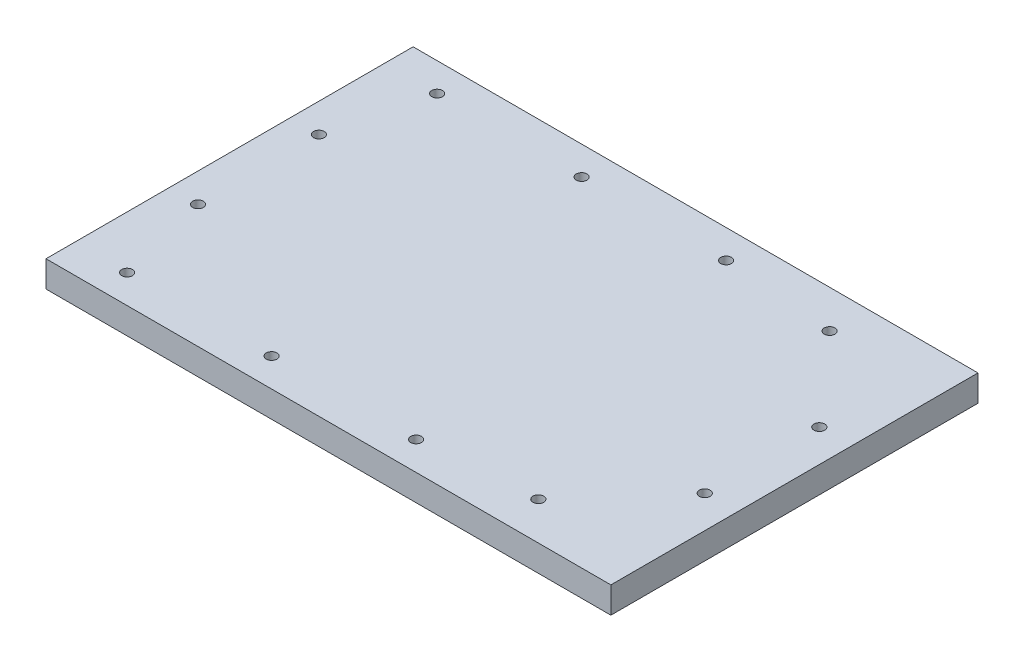
from build123d import *

# Parameters (mm, degrees)
SKETCH2_W               = 215
SKETCH2_H               = 139.732878208
BOSS_EXTRUDE1_DEPTH     = 10
SKETCH3_R               = 2.04999698
SKETCH3_R_2             = 2.049996201
SKETCH3_R_3             = 2.049998036
SKETCH3_R_4             = 2.05000301
SKETCH3_R_5             = 2.05000489
SKETCH3_R_6             = 2.05000167
SKETCH3_R_7             = 2.049998726
SKETCH3_R_8             = 2.050000522
SKETCH3_R_9             = 2.050000228
SKETCH3_R_10            = 2.050000557
SKETCH3_R_11            = 2.050001917
SKETCH3_R_12            = 2.050001502
CUT_EXTRUDE2_DEPTH      = 11
CUT_EXTRUDE2_DEPTH_BACK = 1


with BuildPart() as part:
    # Sketch2 → Boss-Extrude1 (new body)
    with BuildSketch(Plane(origin=(0, 0, 0), x_dir=(1, 0, 0), z_dir=(0, 1, 0))):
        with Locations((107.5, -70)):
            Rectangle(SKETCH2_W, SKETCH2_H)
    extrude(amount=BOSS_EXTRUDE1_DEPTH)

    # Sketch3 → Cut-Extrude2 (cut, two sides)
    with BuildSketch(Plane(origin=(0, 0, 0), x_dir=(1, 0, 0), z_dir=(0, 1, 0))) as cut_extrude2_sk:
        with Locations((20.000003077, -129.000001764)):
            Circle(SKETCH3_R)
        with Locations((74.999999742, -129.000001144)):
            Circle(SKETCH3_R_2)
        with Locations((130.000001864, -128.999997495)):
            Circle(SKETCH3_R_3)
        with Locations((172.961008424, -125.432773785)):
            Circle(SKETCH3_R_4)
        with Locations((202.661132812, -91.812960049)):
            Circle(SKETCH3_R_5)
        with Locations((202.661143569, -48.187042941)):
            Circle(SKETCH3_R_6)
        with Locations((172.961008675, -14.567229705)):
            Circle(SKETCH3_R_7)
        with Locations((130.000001694, -10.999999378)):
            Circle(SKETCH3_R_8)
        with Locations((75.000000263, -10.999999084)):
            Circle(SKETCH3_R_9)
        with Locations((20.000004874, -11.000001196)):
            Circle(SKETCH3_R_10)
        with Locations((10.999999837, -47.000000994)):
            Circle(SKETCH3_R_11)
        with Locations((11.000000285, -93.0000014)):
            Circle(SKETCH3_R_12)
    extrude(amount=CUT_EXTRUDE2_DEPTH, mode=Mode.SUBTRACT)
    extrude(cut_extrude2_sk.sketch, amount=-CUT_EXTRUDE2_DEPTH_BACK, mode=Mode.SUBTRACT)


solid = part.part
